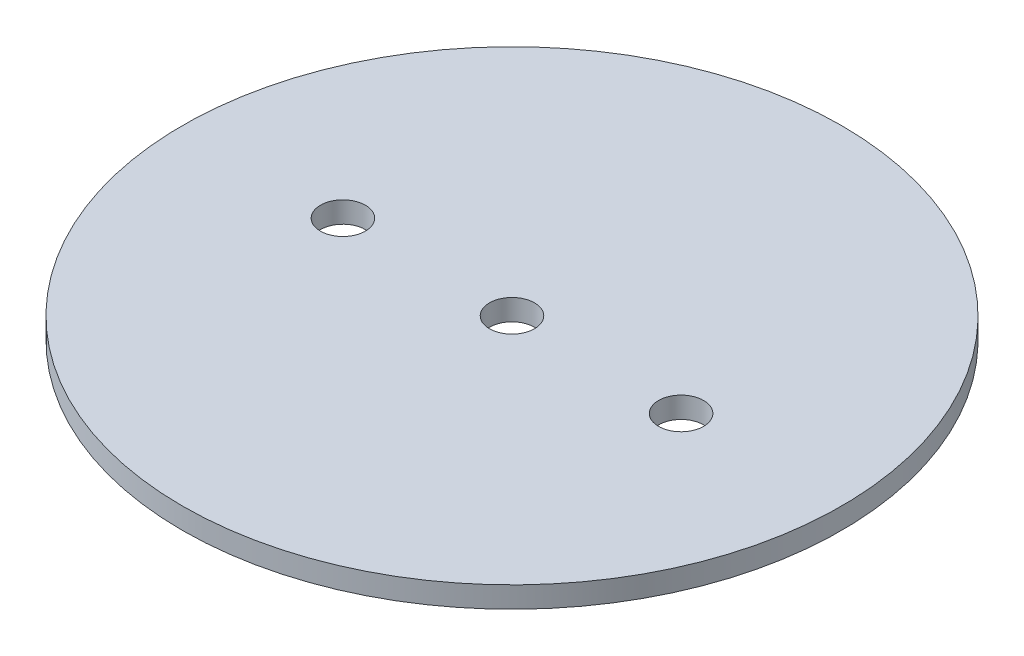
from build123d import *

# Parameters (mm, degrees)
SKETCH1_R               = 49.5046
BOSS_EXTRUDE1_DEPTH     = 3.175
F_1_4_CLEARANCE_HOLE1_D = 6.7564


with BuildPart() as part:
    # Sketch1 → Boss-Extrude1 (new body)
    with BuildSketch(Plane(origin=(0, 0, 0), x_dir=(1, 0, 0), z_dir=(0, 1, 0))):
        Circle(SKETCH1_R)
    extrude(amount=BOSS_EXTRUDE1_DEPTH)

    # 1/4 Clearance Hole1 (through all)
    with Locations(Plane(origin=(0, 0, 0), x_dir=(-1, 0, 0), z_dir=(0, -1, 0))):
        with Locations((-25.4, 0), (0, 0), (25.4, 0)):
            Hole(F_1_4_CLEARANCE_HOLE1_D / 2)


solid = part.part
